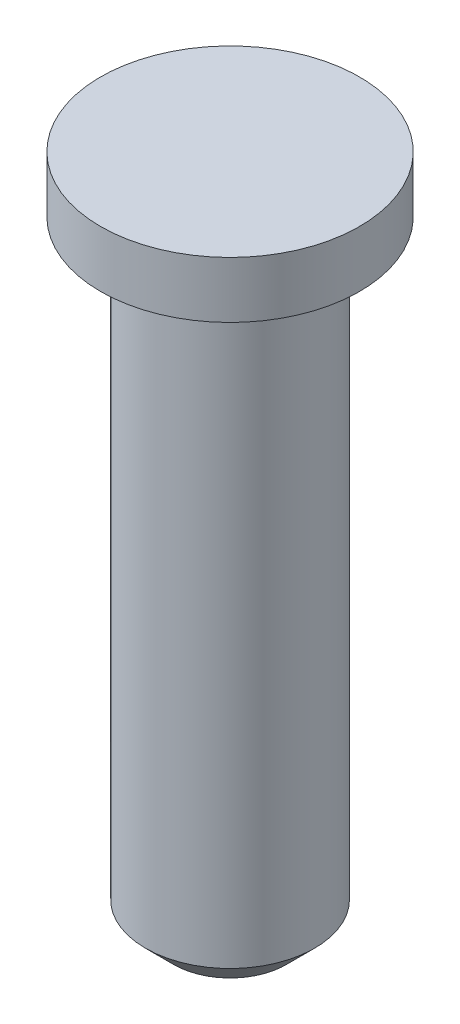
from build123d import *

# Parameters (mm, degrees)
CHAFL_N1_SIZE = 0.5


with BuildPart() as part:
    # Croquis1 → Revolución1 (revolve)
    with BuildSketch(Plane.XY):
        Polygon((0, 0), (2.3, 0), (2.3, -1), (1.5, -1), (1.5, -12), (0, -12), align=None)
    revolve(axis=Axis((0, 0, 0), (0, -1, 0)))

    # Chaflán1
    chafl_n1_edges = [part.edges().sort_by_distance(p)[0] for p in [
        (-1.5, -12, 0),
    ]]
    chamfer(chafl_n1_edges, length=CHAFL_N1_SIZE)


solid = part.part
